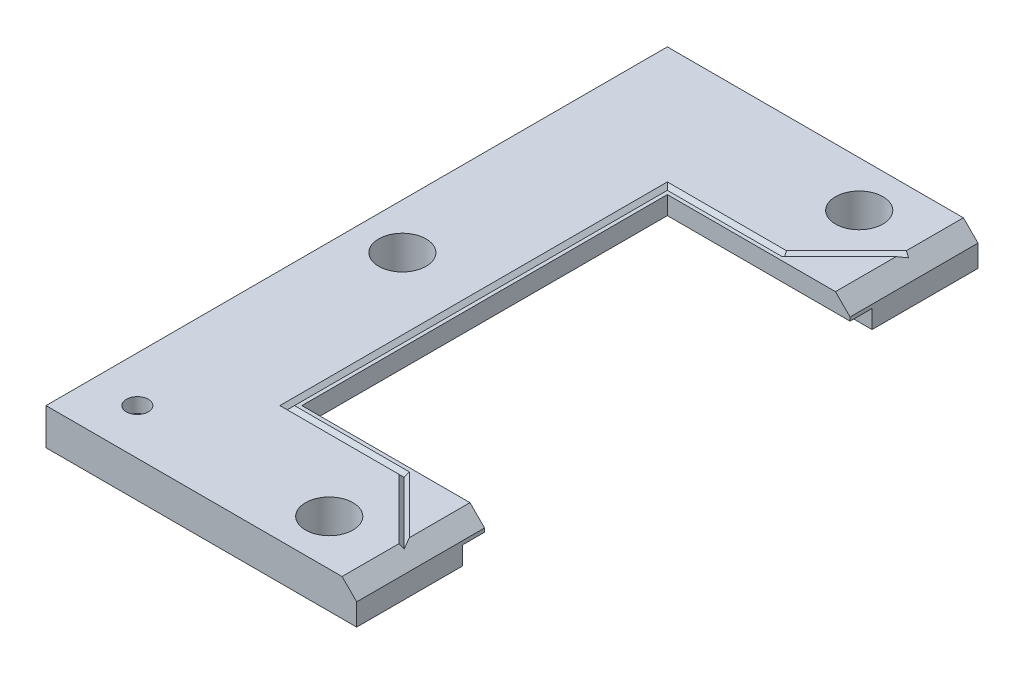
from build123d import *

# Parameters (mm, degrees)
BOSS_EXTRUDE1_DEPTH       = 10
SKETCH3_W                 = 6
SKETCH3_H                 = 5
CHAMFER1_SIZE             = 4
SKETCH10_R                = 6.5
CUT_EXTRUDE1_DEPTH        = 121.623380818
F_6_0MM_DOWEL_HOLE1_D     = 6
F_6_0MM_DOWEL_HOLE1_DEPTH = 4
F_6_0MM_DOWEL_HOLE1_TIP   = 1.802581857


with BuildPart() as part:
    # Sketch1 → Boss-Extrude1 (new body)
    with BuildSketch(Plane(origin=(0, 0, 0), x_dir=(1, 0, 0), z_dir=(0, 1, 0))):
        Polygon((0, -85), (0, -50), (-50, -50), (-50, 50), (0, 50), (0, 85), (-85, 85), (-85, -85), align=None)
    extrude(amount=BOSS_EXTRUDE1_DEPTH)

    # Cut-Sweep1: sweep along a path in Sketch4
    with BuildLine(Plane.XZ) as cut_sweep1_path:
        Line((0, 50), (-50, 50))
        Line((-50, 50), (-50, -50))
        Line((-50, -50), (0, -50))
    # Sketch3 → Cut-Sweep1 (sweep, cut)
    with BuildSketch(Plane(origin=(0, 0, 0), x_dir=(0, 0, -1), z_dir=(1, 0, 0))):
        with Locations((-53, 2.5)):
            Rectangle(SKETCH3_W, SKETCH3_H)
    sweep(path=cut_sweep1_path.line, transition=Transition.RIGHT, mode=Mode.SUBTRACT)

    # Chamfer1
    chamfer1_edges = [part.edges().sort_by_distance(p)[0] for p in [
        (0, 10, 67.5),
        (0, 10, -67.5),
    ]]
    chamfer(chamfer1_edges, length=CHAMFER1_SIZE)

    # Sketch10 → Cut-Extrude1 (cut, through all)
    with BuildSketch(Plane(origin=(0, 10, 0), x_dir=(1, 0, 0), z_dir=(0, 1, 0))):
        with Locations((-72.499960031, 0)):
            Circle(SKETCH10_R)
        with Locations((-20, -72.5)):
            Circle(SKETCH10_R)
        with Locations((-20, 72.5)):
            Circle(SKETCH10_R)
    extrude(amount=-CUT_EXTRUDE1_DEPTH, mode=Mode.SUBTRACT)

    # Ø6.0mm Dowel Hole1
    with Locations(Plane(origin=(0, 10, 0), x_dir=(1, 0, 0), z_dir=(0, 1, 0))):
        with Locations((-72.5, -72.5)):
            Hole(F_6_0MM_DOWEL_HOLE1_D / 2, depth=F_6_0MM_DOWEL_HOLE1_DEPTH)
            with Locations((0, 0, -(F_6_0MM_DOWEL_HOLE1_DEPTH + F_6_0MM_DOWEL_HOLE1_TIP / 2))):  # 118° drill point
                Cone(0, F_6_0MM_DOWEL_HOLE1_D / 2, F_6_0MM_DOWEL_HOLE1_TIP, mode=Mode.SUBTRACT)

    # Cut-Sweep2: sweep along a path in Sketch5
    with BuildLine(Plane(origin=(0, 10, 0), x_dir=(1, 0, 0), z_dir=(0, 1, 0))) as cut_sweep2_path:
        Line((0, -72), (-20, -52))
        Line((-20, -52), (-52, -52))
        Line((-52, -52), (-52, 52))
        Line((-52, 52), (-20, 52))
        Line((-20, 52), (0, 72))
    # Sketch9 → Cut-Sweep2 (sweep, cut)
    with BuildSketch(Plane(origin=(36, 0, 36), x_dir=(0, -1, 0), z_dir=(0.7071067811865462, 0, 0.7071067811865489))):
        Polygon((-10, -50.911688245), (-10, -51.911688245), (-9, -50.911688245), (-10, -49.911688245), align=None)
    sweep(path=cut_sweep2_path.line, transition=Transition.RIGHT, mode=Mode.SUBTRACT)


solid = part.part
